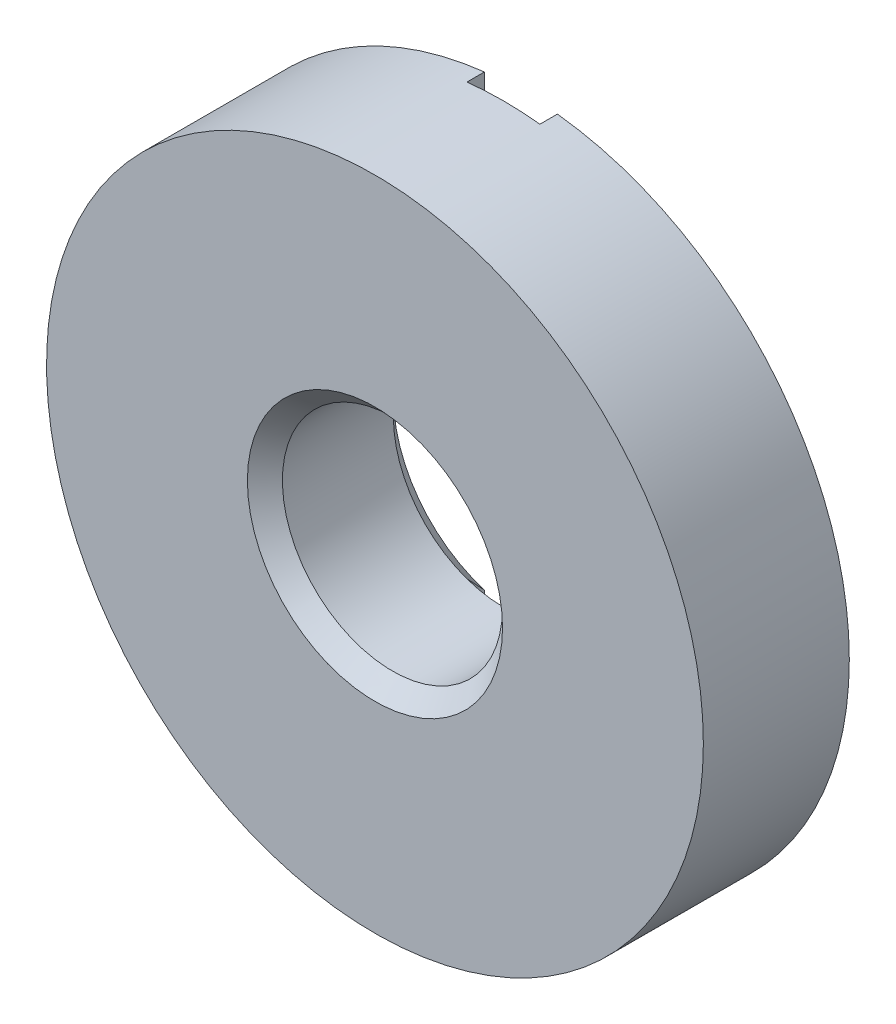
from build123d import *

# Parameters (mm, degrees)
SKETCH1_R          = 14.2875
SKETCH1_R_2        = 4.7879
EXTRUDE1_DEPTH     = 6.35
CHAMFER2_SIZE      = 0.762
SKETCH2_W          = 3.175
SKETCH2_H          = 28.575
CUT_EXTRUDE1_DEPTH = 0.762


with BuildPart() as part:
    # Sketch1 → Extrude1 (new body)
    with BuildSketch(Plane.XY):
        with Locations(Location((0, 0, 0), (0, 0, 96.379370208))):  # turned: the seam where the file's is
            Circle(SKETCH1_R)
        with Locations(Location((0, 0, 0), (0, 0, 109.363791367))):  # turned: the seam where the file's is
            Circle(SKETCH1_R_2, mode=Mode.SUBTRACT)
    extrude(amount=EXTRUDE1_DEPTH)

    # Chamfer2
    chamfer2_edges = [part.edges().sort_by_distance(p)[0] for p in [
        (1.5875, -4.517059902, 0),
        (1.5875, -4.517059902, 6.35),
    ]]
    chamfer(chamfer2_edges, length=CHAMFER2_SIZE)

    # Sketch2 → Cut-Extrude1 (cut)
    with BuildSketch(Plane(origin=(0, 0, 0), x_dir=(-1, 0, 0), z_dir=(0, 0, -1))):
        Rectangle(SKETCH2_W, SKETCH2_H)
    extrude(amount=-CUT_EXTRUDE1_DEPTH, mode=Mode.SUBTRACT)


solid = part.part
